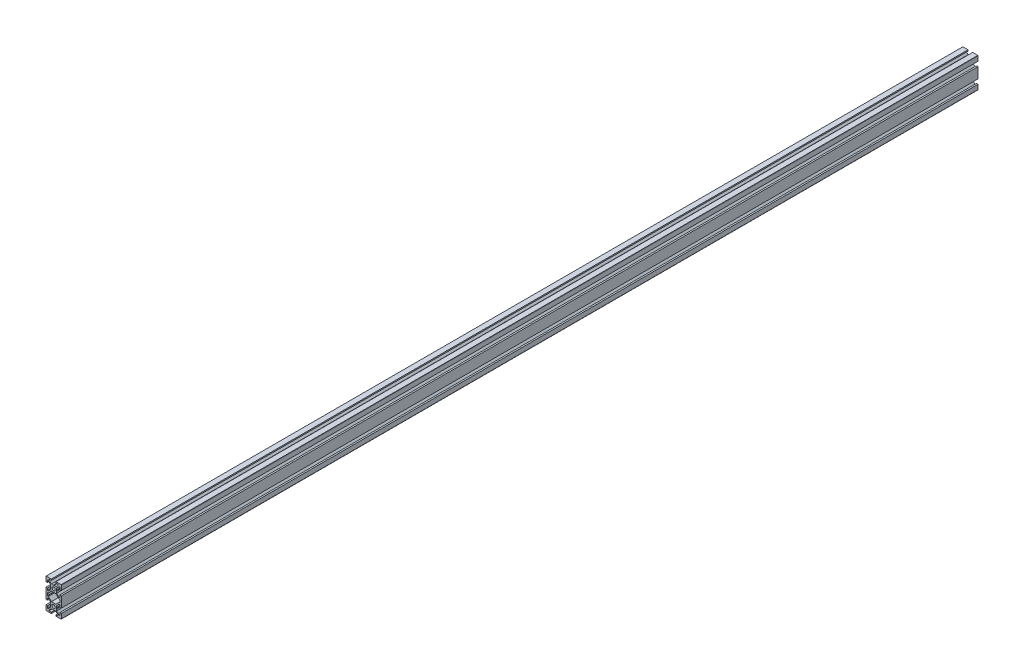
from build123d import *

# Parameters (mm, degrees)
SKETCH1_R           = 2.1
BOSS_EXTRUDE1_DEPTH = 1200


with BuildPart() as part:
    # Sketch1 → Boss-Extrude1 (new body)
    with BuildSketch(Plane(origin=(0, 0, -1000), x_dir=(-1, 0, 0), z_dir=(0, 0, -1))):
        with BuildLine():
            Line((10, -7), (10, 7))
            Line((10, 7), (8, 7))
            Line((8, 7), (8, 4))
            Line((8, 4), (7.060660172, 4))
            Line((7.060660172, 4), (4, 7.060660172))
            Line((4, 7.060660172), (4, 9.480384758))
            Line((4, 9.480384758), (3.7, 10))
            Line((3.7, 10), (4, 10.519615242))
            Line((4, 10.519615242), (4, 12.939339828))
            Line((4, 12.939339828), (7.060660172, 16))
            Line((7.060660172, 16), (8, 16))
            Line((8, 16), (8, 13))
            Line((8, 13), (10, 13))
            Line((10, 13), (10, 19))
            ThreePointArc((10, 19), (9.948683298, 19.316227766), (9.8, 19.6))
            Line((9.8, 19.6), (3, 19.6))
            Line((3, 19.6), (3, 18))
            Line((3, 18), (6, 18))
            Line((6, 18), (6, 17.060660172))
            Line((6, 17.060660172), (2.939339828, 14))
            Line((2.939339828, 14), (0.519615242, 14))
            Line((0.519615242, 14), (0, 13.7))
            Line((0, 13.7), (-0.519615242, 14))
            Line((-0.519615242, 14), (-2.939339828, 14))
            Line((-2.939339828, 14), (-6, 17.060660172))
            Line((-6, 17.060660172), (-6, 18))
            Line((-6, 18), (-3, 18))
            Line((-3, 18), (-3, 19.6))
            Line((-3, 19.6), (-9.8, 19.6))
            ThreePointArc((-9.8, 19.6), (-9.948683298, 19.316227766), (-10, 19))
            Line((-10, 19), (-10, 13))
            Line((-10, 13), (-8, 13))
            Line((-8, 13), (-8, 16))
            Line((-8, 16), (-7.060660172, 16))
            Line((-7.060660172, 16), (-4, 12.939339828))
            Line((-4, 12.939339828), (-4, 10.519615242))
            Line((-4, 10.519615242), (-3.7, 10))
            Line((-3.7, 10), (-4, 9.480384758))
            Line((-4, 9.480384758), (-4, 7.060660172))
            Line((-4, 7.060660172), (-7.060660172, 4))
            Line((-7.060660172, 4), (-8, 4))
            Line((-8, 4), (-8, 7))
            Line((-8, 7), (-10, 7))
            Line((-10, 7), (-10, -7))
            Line((-10, -7), (-8, -7))
            Line((-8, -7), (-8, -4))
            Line((-8, -4), (-7.060660172, -4))
            Line((-7.060660172, -4), (-4, -7.060660172))
            Line((-4, -7.060660172), (-4, -9.480384758))
            Line((-4, -9.480384758), (-3.7, -10))
            Line((-3.7, -10), (-4, -10.519615242))
            Line((-4, -10.519615242), (-4, -12.939339828))
            Line((-4, -12.939339828), (-7.060660172, -16))
            Line((-7.060660172, -16), (-8, -16))
            Line((-8, -16), (-8, -13))
            Line((-8, -13), (-10, -13))
            Line((-10, -13), (-10, -19))
            ThreePointArc((-10, -19), (-9.948683298, -19.316227766), (-9.8, -19.6))
            Line((-9.8, -19.6), (-3, -19.6))
            Line((-3, -19.6), (-3, -18))
            Line((-3, -18), (-6, -18))
            Line((-6, -18), (-6, -17.060660172))
            Line((-6, -17.060660172), (-2.939339828, -14))
            Line((-2.939339828, -14), (-0.519615242, -14))
            Line((-0.519615242, -14), (0, -13.7))
            Line((0, -13.7), (0.519615242, -14))
            Line((0.519615242, -14), (2.939339828, -14))
            Line((2.939339828, -14), (6, -17.060660172))
            Line((6, -17.060660172), (6, -18))
            Line((6, -18), (3, -18))
            Line((3, -18), (3, -19.6))
            Line((3, -19.6), (9.8, -19.6))
            ThreePointArc((9.8, -19.6), (9.948683298, -19.316227766), (10, -19))
            Line((10, -19), (10, -13))
            Line((10, -13), (8, -13))
            Line((8, -13), (8, -16))
            Line((8, -16), (7.060660172, -16))
            Line((7.060660172, -16), (4, -12.939339828))
            Line((4, -12.939339828), (4, -10.519615242))
            Line((4, -10.519615242), (3.7, -10))
            Line((3.7, -10), (4, -9.480384758))
            Line((4, -9.480384758), (4, -7.060660172))
            Line((4, -7.060660172), (7.060660172, -4))
            Line((7.060660172, -4), (8, -4))
            Line((8, -4), (8, -7))
            Line((8, -7), (10, -7))
        make_face()
        with Locations((0, -10)):
            Circle(SKETCH1_R, mode=Mode.SUBTRACT)
        with Locations((0, 10)):
            Circle(SKETCH1_R, mode=Mode.SUBTRACT)
        with BuildLine():
            Line((8, 1.7), (8, -1.7))
            ThreePointArc((8, -1.7), (7.912132034, -1.912132034), (7.7, -2))
            Line((7.7, -2), (7.063603897, -2))
            ThreePointArc((7.063603897, -2), (6.948798867, -2.02283614), (6.851471863, -2.087867966))
            Line((6.851471863, -2.087867966), (2.939339828, -6))
            Line((2.939339828, -6), (-2.939339828, -6))
            Line((-2.939339828, -6), (-6.851471863, -2.087867966))
            ThreePointArc((-6.851471863, -2.087867966), (-6.948798867, -2.02283614), (-7.063603897, -2))
            Line((-7.063603897, -2), (-7.7, -2))
            ThreePointArc((-7.7, -2), (-7.912132034, -1.912132034), (-8, -1.7))
            Line((-8, -1.7), (-8, 1.7))
            ThreePointArc((-8, 1.7), (-7.912132034, 1.912132034), (-7.7, 2))
            Line((-7.7, 2), (-7.063603897, 2))
            ThreePointArc((-7.063603897, 2), (-6.948798867, 2.02283614), (-6.851471863, 2.087867966))
            Line((-6.851471863, 2.087867966), (-2.939339828, 6))
            Line((-2.939339828, 6), (2.939339828, 6))
            Line((2.939339828, 6), (6.851471863, 2.087867966))
            ThreePointArc((6.851471863, 2.087867966), (6.948798867, 2.02283614), (7.063603897, 2))
            Line((7.063603897, 2), (7.7, 2))
            ThreePointArc((7.7, 2), (7.912132034, 1.912132034), (8, 1.7))
        make_face(mode=Mode.SUBTRACT)
    extrude(amount=-BOSS_EXTRUDE1_DEPTH)


solid = part.part
